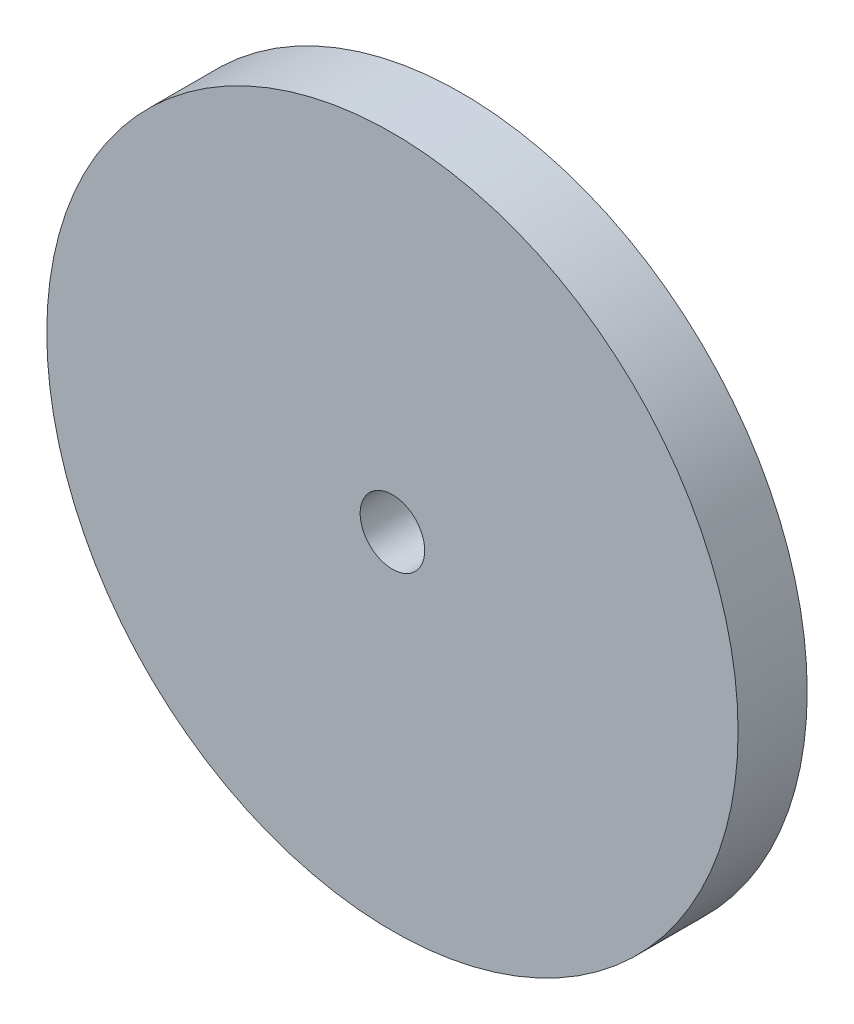
from build123d import *

# Parameters (mm, degrees)
ESQUISSE1_R        = 15
ESQUISSE1_R_2      = 1.4
BOSS_EXTRU_1_DEPTH = 3


with BuildPart() as part:
    # Esquisse1 → Boss.-Extru.1 (new body)
    with BuildSketch(Plane.XY):
        Circle(ESQUISSE1_R)
        Circle(ESQUISSE1_R_2, mode=Mode.SUBTRACT)
    extrude(amount=BOSS_EXTRU_1_DEPTH)


solid = part.part
